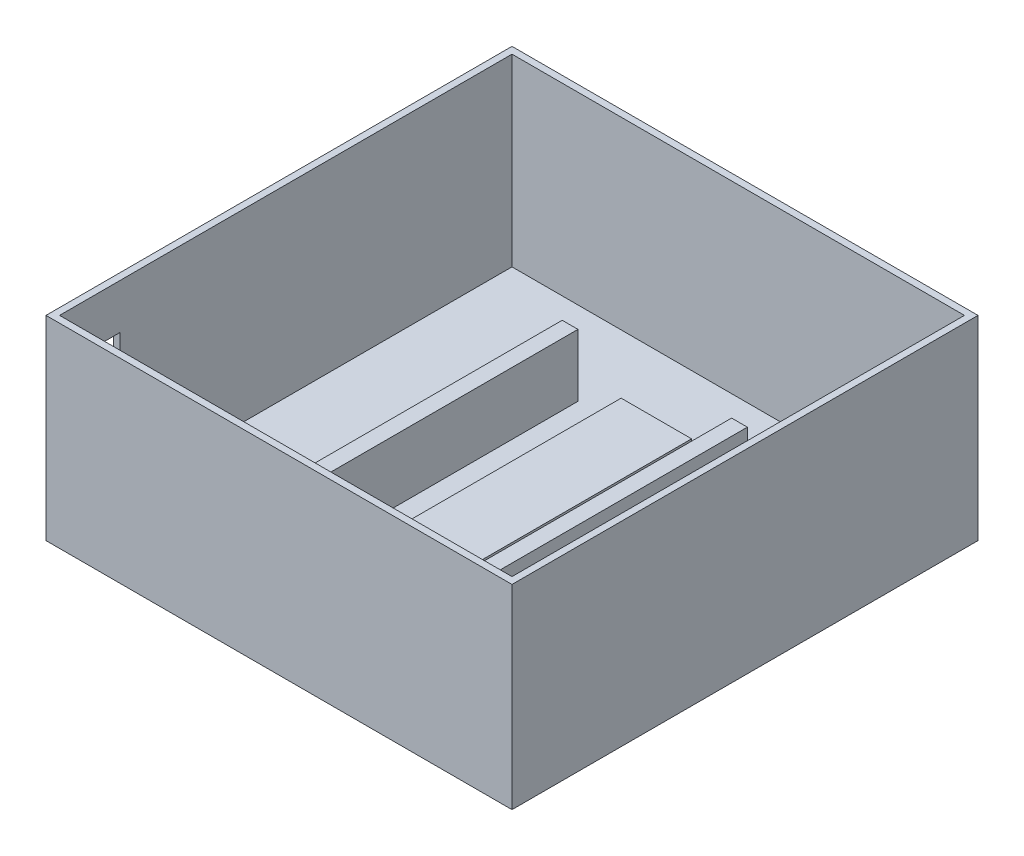
from build123d import *

# Parameters (mm, degrees)
SKETCH1_W             = 86
SKETCH1_H             = 86
BOSS_EXTRUDE1_DEPTH   = 36
SKETCH3_W             = 83.5
SKETCH3_H             = 83.5
CUT_EXTRUDE1_DEPTH    = 34
SKETCH4_W             = 13
SKETCH4_H             = 53.28405224
BOSS_EXTRUDE2_DEPTH   = 4.2
BOSS_EXTRUDE4_START   = -4.2
SKETCH5_W             = 2.90534636
SKETCH5_H             = 52.702982968
BOSS_EXTRUDE4_DEPTH   = 11.5
BOSS_EXTRUDE4_2_DEPTH = 11.5
SKETCH7_W             = 8
SKETCH7_H             = 10.5
CUT_EXTRUDE2_DEPTH    = 2


with BuildPart() as part:
    # Sketch1 → Boss-Extrude1 (new body)
    with BuildSketch(Plane(origin=(0, 0, 0), x_dir=(1, 0, 0), z_dir=(0, 1, 0))):
        Rectangle(SKETCH1_W, SKETCH1_H)
    extrude(amount=BOSS_EXTRUDE1_DEPTH)

    # Sketch3 → Cut-Extrude1 (cut)
    with BuildSketch(Plane(origin=(0, 36, 0), x_dir=(1, 0, 0), z_dir=(0, 1, 0))):
        Rectangle(SKETCH3_W, SKETCH3_H)
    extrude(amount=-CUT_EXTRUDE1_DEPTH, mode=Mode.SUBTRACT)

    # Sketch4 → Boss-Extrude2 (add)
    with BuildSketch(Plane(origin=(0, 2, 0), x_dir=(1, 0, 0), z_dir=(0, 1, 0))):
        Rectangle(SKETCH4_W, SKETCH4_H)
    extrude(amount=BOSS_EXTRUDE2_DEPTH)

    # Sketch7 → Cut-Extrude2 (cut)
    with BuildSketch(Plane.ZY.offset(43)):
        with Locations((34.569793539, 22.43634464)):
            Rectangle(SKETCH7_W, SKETCH7_H)
    extrude(amount=-CUT_EXTRUDE2_DEPTH, mode=Mode.SUBTRACT)


with BuildPart() as body_2:
    # Sketch5 → Boss-Extrude4 (new body)
    with BuildSketch(Plane(origin=(0, 6.2, 0), x_dir=(1, 0, 0), z_dir=(0, 1, 0)).offset(BOSS_EXTRUDE4_START)):
        with Locations((15.630763416, 0)):
            Rectangle(SKETCH5_W, SKETCH5_H)
    extrude(amount=BOSS_EXTRUDE4_DEPTH)


with BuildPart() as body_3:
    # Sketch5 → Boss-Extrude4 2 (new body)
    with BuildSketch(Plane(origin=(0, 6.2, 0), x_dir=(1, 0, 0), z_dir=(0, 1, 0)).offset(BOSS_EXTRUDE4_START)):
        with Locations((-15.630763416, 0)):
            Rectangle(SKETCH5_W, SKETCH5_H)
    extrude(amount=BOSS_EXTRUDE4_2_DEPTH)


solid = Compound([part.part, body_2.part, body_3.part])
